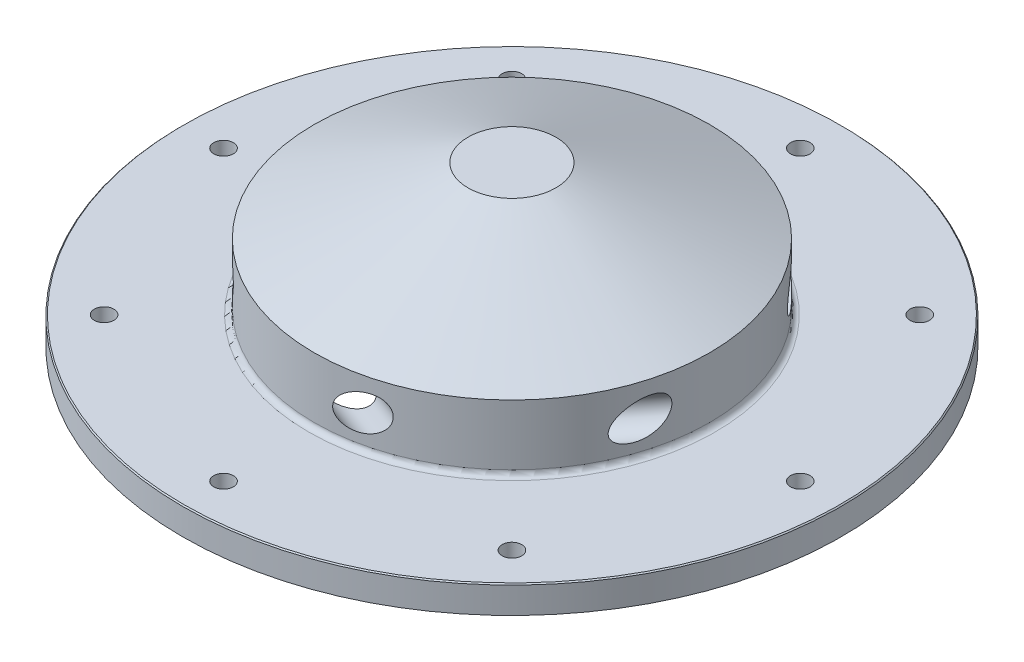
from build123d import *

# Parameters (mm, degrees)
SKETCH2_R                 = 38.1
BOSS_EXTRUDE1_DEPTH       = 3.175
TAP_DRILL_FOR_4_40_TAP1_D = 2.2606
CIRPATTERN1_COUNT         = 8
SKETCH7_R                 = 22.86
BOSS_EXTRUDE2_DEPTH       = 7.62
SKETCH8_R                 = 19.05
CUT_EXTRUDE1_DEPTH        = 8.89
SKETCH14_R                = 5.08
SKETCH13_R                = 22.86
FILLET1_R                 = 0.635
CHAMFER1_SIZE             = 0.127
FILLET2_R                 = 0.635
SKETCH16_R                = 1.984375
CUT_EXTRUDE2_DEPTH        = 40.595725599
CIRPATTERN2_COUNT         = 6


with BuildPart() as part:
    # Sketch2 → Boss-Extrude1 (new body)
    with BuildSketch(Plane(origin=(0, 0, 0), x_dir=(1, 0, 0), z_dir=(0, 1, 0))):
        Circle(SKETCH2_R)
    extrude(amount=BOSS_EXTRUDE1_DEPTH)

    # Tap Drill for _4-40 Tap1 (through all)
    with Locations(Plane(origin=(0, 0, 0), x_dir=(-1, 0, 0), z_dir=(0, -1, 0))):
        with Locations((0, -33.3375)):
            tap_drill_for_4_40_tap1 = Hole(TAP_DRILL_FOR_4_40_TAP1_D / 2)

    # CirPattern1: Tap Drill for _4-40 Tap1 ×8 about axis
    cirpattern1_axis = Axis((0, 0, 0), (0, 1, 0))
    for i in range(1, CIRPATTERN1_COUNT):
        add(tap_drill_for_4_40_tap1.rotate(cirpattern1_axis, i * 360 / CIRPATTERN1_COUNT), mode=Mode.SUBTRACT)

    # Sketch7 → Boss-Extrude2 (add)
    with BuildSketch(Plane(origin=(0, 3.175, 0), x_dir=(1, 0, 0), z_dir=(0, 1, 0))):
        Circle(SKETCH7_R)
    extrude(amount=BOSS_EXTRUDE2_DEPTH)

    # Sketch8 → Cut-Extrude1 (cut)
    with BuildSketch(Plane.XZ):
        Circle(SKETCH8_R)
    extrude(amount=-CUT_EXTRUDE1_DEPTH, mode=Mode.SUBTRACT)

    # Sketch14 → Loft2 section 0
    with BuildSketch(Plane(origin=(0, 18.415, 0), x_dir=(1, 0, 0), z_dir=(0, 1, 0))):
        Circle(SKETCH14_R)
    # Sketch13 → Loft2 section 1
    with BuildSketch(Plane(origin=(0, 10.795, 0), x_dir=(1, 0, 0), z_dir=(0, 1, 0))):
        Circle(SKETCH13_R)
    loft()

    # Fillet1
    fillet1_edges = [part.edges().sort_by_distance(p)[0] for p in [
        (-19.05, 8.89, 0),
    ]]
    fillet(fillet1_edges, radius=FILLET1_R)

    # Chamfer1
    chamfer1_edges = [part.edges().sort_by_distance(p)[0] for p in [
        (-38.1, 3.175, 0),
    ]]
    chamfer(chamfer1_edges, length=CHAMFER1_SIZE)

    # Fillet2
    fillet2_edges = [part.edges().sort_by_distance(p)[0] for p in [
        (-22.86, 3.175, 0),
    ]]
    fillet(fillet2_edges, radius=FILLET2_R)

    # Sketch16 → Cut-Extrude2 (cut, through all)
    with BuildSketch(Plane(origin=(0, 0.510443212, 1.905), x_dir=(-1, 0, 0), z_dir=(0, 0.258819045, 0.965925826))):
        with Locations((16.711999311, -2.789932638)):
            Circle(SKETCH16_R)
    cut_extrude2 = extrude(amount=CUT_EXTRUDE2_DEPTH, mode=Mode.SUBTRACT)

    # CirPattern2: Cut-Extrude2 ×6 about axis
    cirpattern2_axis = Axis((0, 0, 0), (0, 1, 0))
    for i in range(1, CIRPATTERN2_COUNT):
        add(cut_extrude2.rotate(cirpattern2_axis, i * 360 / CIRPATTERN2_COUNT), mode=Mode.SUBTRACT)


solid = part.part
